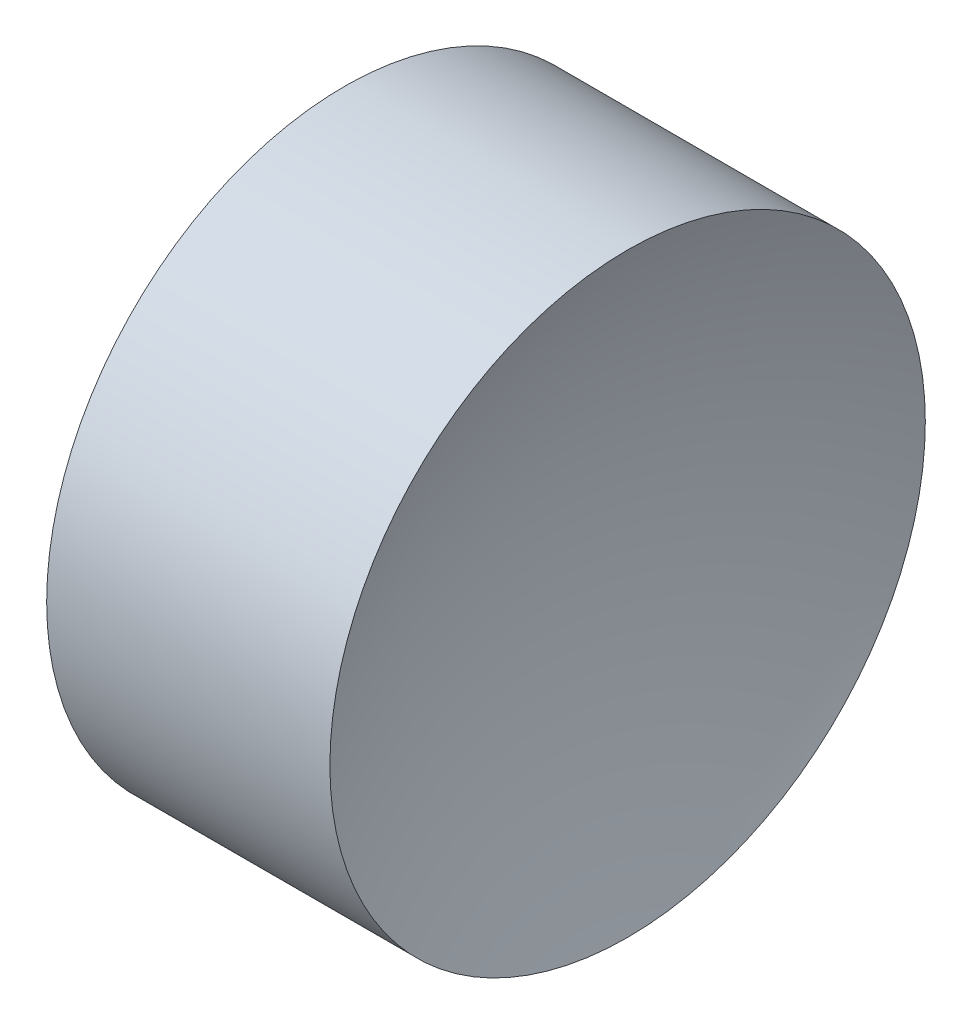
from build123d import *


with BuildPart() as part:
    # 草图1 → 旋转1 (revolve)
    with BuildSketch(Plane.XY, mode=Mode.PRIVATE) as revolve_1_sk:
        with BuildLine():
            Line((11.156989876, 6.515563046), (11.156989876, 8.515563046))
            Line((11.156989876, 8.515563046), (13.059506263, 8.515563046))
            ThreePointArc((13.059506263, 8.515563046), (12.758617836, 7.535614447), (12.656989876, 6.515563046))
            Line((12.656989876, 6.515563046), (11.156989876, 6.515563046))
        make_face()
    revolve(revolve_1_sk.sketch.rotate(Axis((10.342015318, 6.515563046, 0), (1, 0, 0)), 180), axis=Axis((10.342015318, 6.515563046, 0), (1, 0, 0)))  # turned: the seam where the file's is


solid = part.part
